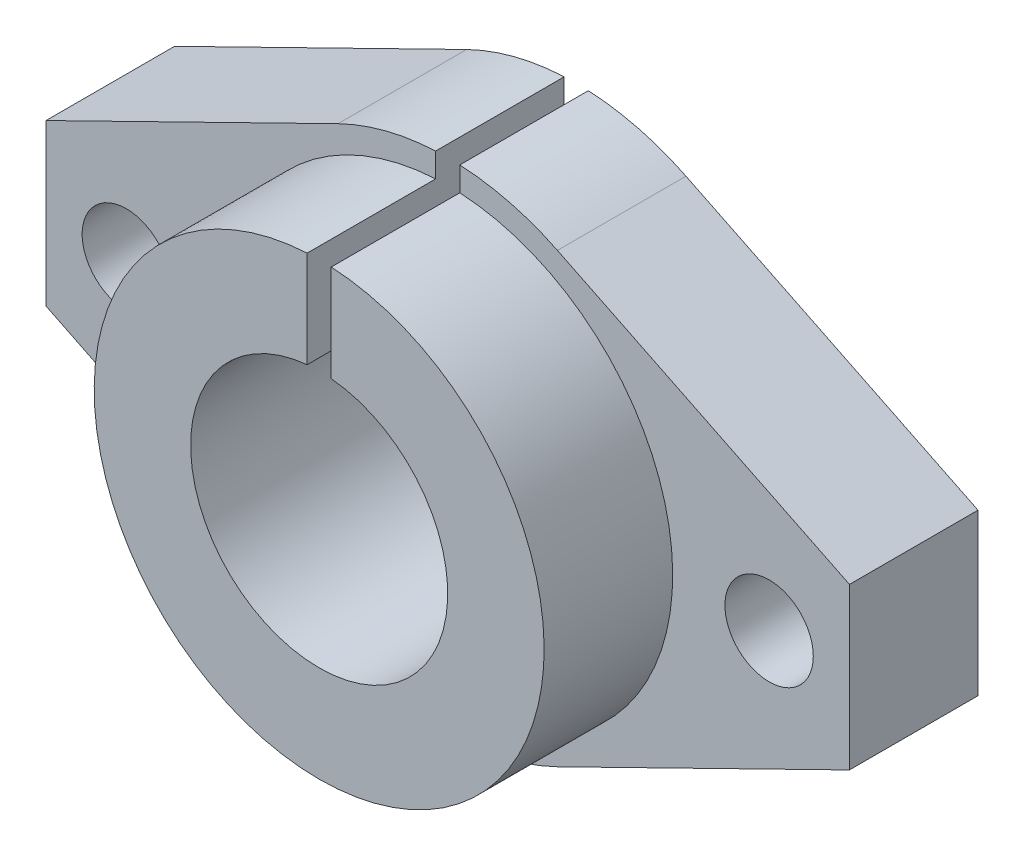
from build123d import *

# Parameters (mm, degrees)
BOSS_EXTRUDE1_DEPTH = 8
SKETCH2_R           = 14
BOSS_EXTRUDE2_DEPTH = 8
SKETCH3_R           = 8
CUT_EXTRUDE1_DEPTH  = 17
SKETCH4_R           = 2.75
CUT_EXTRUDE2_DEPTH  = 9
SKETCH5_W           = 1.5
SKETCH5_H           = 20
CUT_EXTRUDE3_DEPTH  = 17


with BuildPart() as part:
    # Sketch1 → Boss-Extrude1 (new body)
    with BuildSketch(Plane.XY):
        with BuildLine():
            Line((-6.826881704, 13.915591478), (-25, 5))
            Line((-25, 5), (-25, -5))
            Line((-25, -5), (-6.826881704, -13.915591478))
            ThreePointArc((-6.826881704, -13.915591478), (0, -15.5), (6.826881704, -13.915591478))
            Line((6.826881704, -13.915591478), (25, -5))
            Line((25, -5), (25, 5))
            Line((25, 5), (6.826881704, 13.915591478))
            ThreePointArc((6.826881704, 13.915591478), (0, 15.5), (-6.826881704, 13.915591478))
        make_face()
    extrude(amount=BOSS_EXTRUDE1_DEPTH)

    # Sketch2 → Boss-Extrude2 (add)
    with BuildSketch(Plane.XY.offset(8)):
        Circle(SKETCH2_R)
    extrude(amount=BOSS_EXTRUDE2_DEPTH)

    # Sketch3 → Cut-Extrude1 (cut, through all)
    with BuildSketch(Plane.XY.offset(16)):
        Circle(SKETCH3_R)
    extrude(amount=-CUT_EXTRUDE1_DEPTH, mode=Mode.SUBTRACT)

    # Sketch4 → Cut-Extrude2 (cut, through all)
    with BuildSketch(Plane.XY.offset(8)):
        with Locations((-20, 0)):
            Circle(SKETCH4_R)
        with Locations((20, 0)):
            Circle(SKETCH4_R)
    extrude(amount=-CUT_EXTRUDE2_DEPTH, mode=Mode.SUBTRACT)

    # Sketch5 → Cut-Extrude3 (cut, through all)
    with BuildSketch(Plane.XY.offset(16)):
        with Locations((0, 15)):
            Rectangle(SKETCH5_W, SKETCH5_H)
    extrude(amount=-CUT_EXTRUDE3_DEPTH, mode=Mode.SUBTRACT)


solid = part.part
